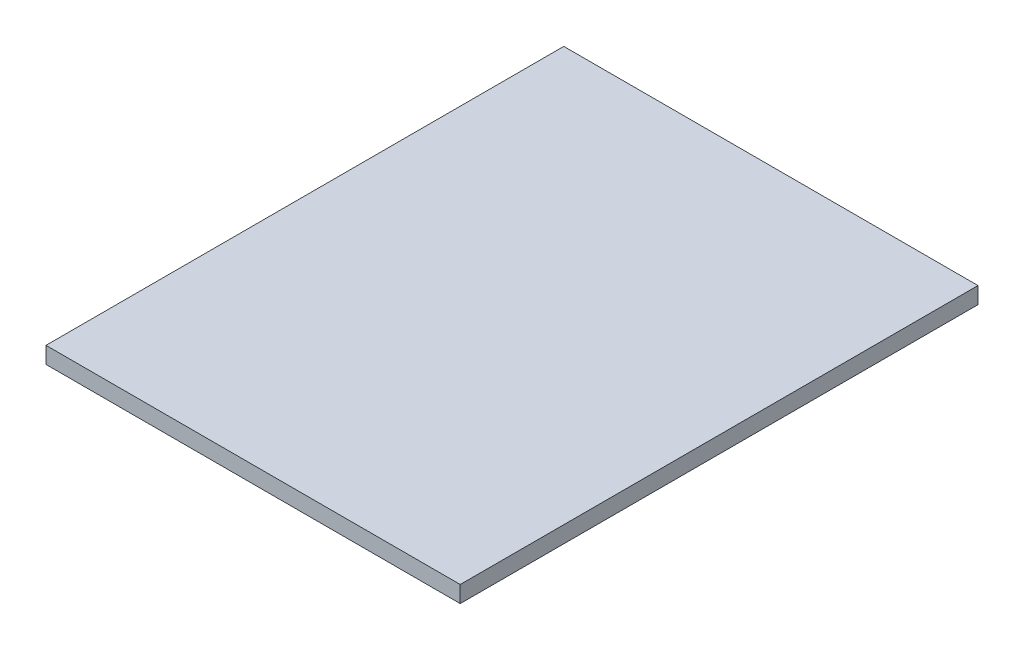
from build123d import *

# Parameters (mm, degrees)
SKETCH1_W           = 101.6
SKETCH1_H           = 127
BOSS_EXTRUDE1_DEPTH = 4.064


with BuildPart() as part:
    # Sketch1 → Boss-Extrude1 (new body)
    with BuildSketch(Plane(origin=(0, 0, 0), x_dir=(1, 0, 0), z_dir=(0, 1, 0))):
        with Locations((50.8, 63.5)):
            Rectangle(SKETCH1_W, SKETCH1_H)
    extrude(amount=BOSS_EXTRUDE1_DEPTH)


solid = part.part
